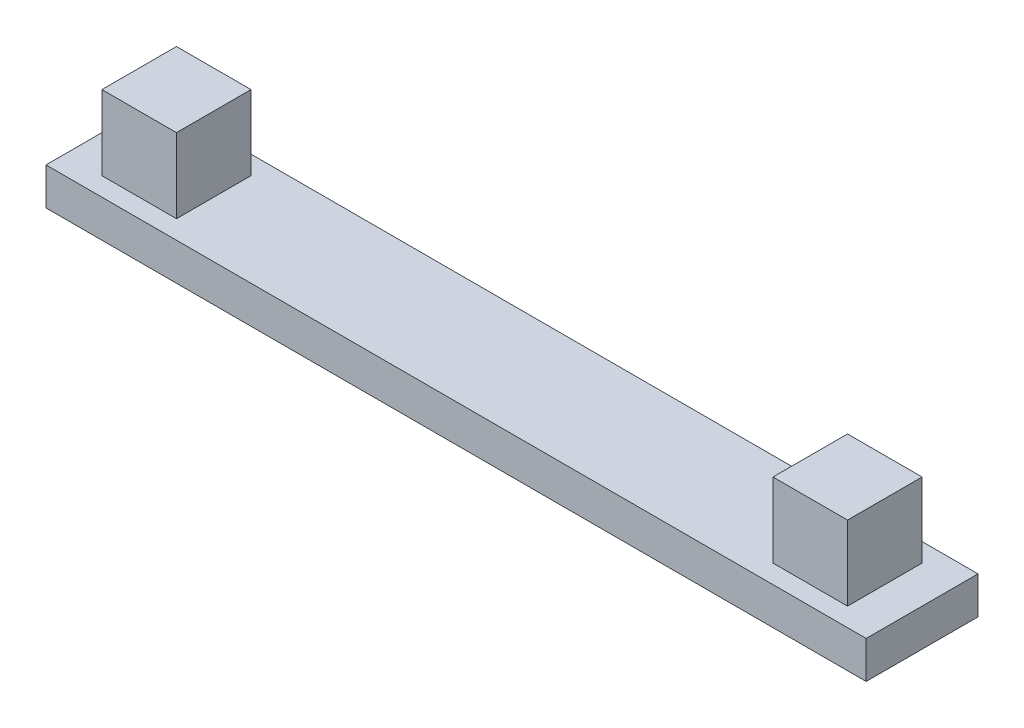
from build123d import *

# Parameters (mm, degrees)
SKETCH1_W           = 22
SKETCH1_H           = 3
SKETCH1_W_2         = 2
SKETCH1_H_2         = 2
BOSS_EXTRUDE1_DEPTH = 1
SKETCH1_3_W         = 2
SKETCH1_3_H         = 2
BOSS_EXTRUDE2_DEPTH = 3


with BuildPart() as part:
    # Sketch1 → Boss-Extrude1 (new body)
    with BuildSketch(Plane(origin=(0, 0, 0), x_dir=(1, 0, 0), z_dir=(0, 1, 0))):
        with Locations((11, 1.5)):
            Rectangle(SKETCH1_W, SKETCH1_H)
        with Locations((2, 1.5)):
            Rectangle(SKETCH1_W_2, SKETCH1_H_2, mode=Mode.SUBTRACT)
        with Locations((20, 1.5)):
            Rectangle(SKETCH1_W_2, SKETCH1_H_2, mode=Mode.SUBTRACT)
    extrude(amount=BOSS_EXTRUDE1_DEPTH)

    # Sketch1_3 → Boss-Extrude2 (add)
    with BuildSketch(Plane(origin=(0, 0, 0), x_dir=(1, 0, 0), z_dir=(0, 1, 0))):
        with Locations((2, 1.5)):
            Rectangle(SKETCH1_3_W, SKETCH1_3_H)
        with Locations((20, 1.5)):
            Rectangle(SKETCH1_3_W, SKETCH1_3_H)
    extrude(amount=BOSS_EXTRUDE2_DEPTH)


solid = part.part
